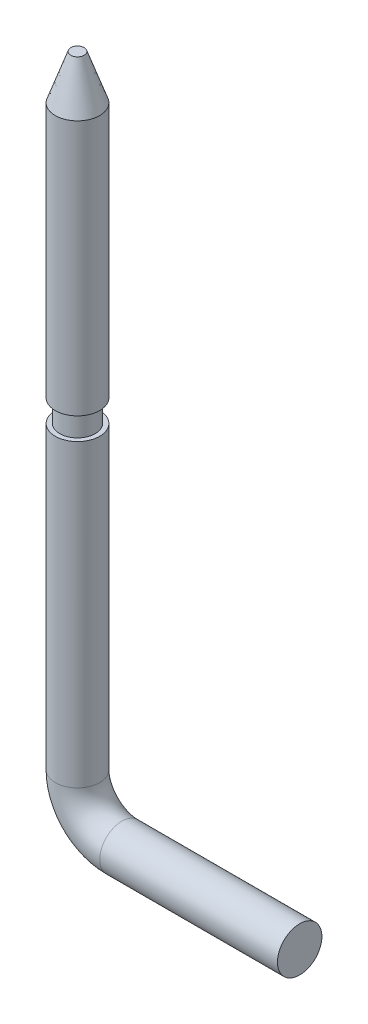
from build123d import *

# Parameters (mm, degrees)
SKETCH2_R = 1
SKETCH3_W = 0.2
SKETCH3_H = 1


with BuildPart() as part:
    # Sweep1: sweep along a path in Sketch1
    with BuildLine(Plane.XY) as sweep1_path:
        Line((0, 30), (0, 2))
        ThreePointArc((0, 2), (0.585786438, 0.585786438), (2, 0))
        Line((2, 0), (10, 0))
    # Sketch2 → Sweep1 (sweep)
    with BuildSketch(Plane(origin=(10, 0, 0), x_dir=(0, 0, -1), z_dir=(1, 0, 0))):
        Circle(SKETCH2_R)
    sweep(path=sweep1_path.line)

    # Sketch3 → Cut-Revolve1 (revolve, cut)
    with BuildSketch(Plane.XY):
        Polygon((-0.3, 30), (-1, 28), (-1, 30), align=None)
        with Locations((-0.9, 16)):
            Rectangle(SKETCH3_W, SKETCH3_H)
    revolve(axis=Axis((0, 30, 0), (0, -1, 0)), mode=Mode.SUBTRACT)


solid = part.part
